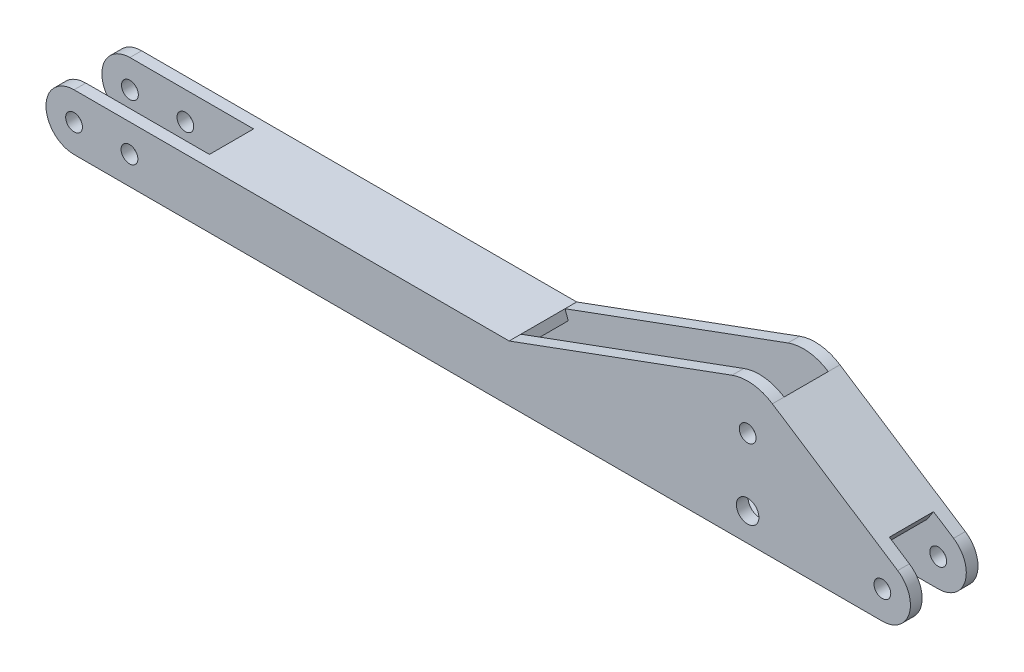
from build123d import *

# Parameters (mm, degrees)
SKETCH1_R           = 38
SKETCH1_R_2         = 51
BOSS_EXTRUDE1_DEPTH = 306
SKETCH2_W           = 687
SKETCH2_H           = 200
CUT_EXTRUDE1_DEPTH  = 214
CUT_EXTRUDE2_START  = -53
SKETCH3_R           = 38
CUT_EXTRUDE2_DEPTH  = 200
SKETCH4_W           = 200
SKETCH4_H           = 174
CUT_EXTRUDE3_DEPTH  = 2690
CUT_EXTRUDE4_REACH  = 866.474
SKETCH5_W           = 1239.54
SKETCH5_H           = 200
SKETCH6_W           = 200
SKETCH6_H           = 296.394261921
CUT_EXTRUDE5_DEPTH  = 2690


with BuildPart() as part:
    # Sketch1 → Boss-Extrude1 (new body)
    with BuildSketch(Plane.XY):
        with BuildLine():
            Line((0, 127), (1970, 127))
            Line((1970, 127), (2979.369630846, 497.448307224))
            ThreePointArc((2979.369630846, 497.448307224), (3073.168771089, 508.686543606), (3162.047709692, 476.669189876))
            Line((3162.047709692, 476.669189876), (3729.41492259, 106.351156655))
            ThreePointArc((3729.41492259, 106.351156655), (3781.728379795, -36.210517152), (3660, -127))
            Line((3660, -127), (0, -127))
            ThreePointArc((0, -127), (-127, 0), (0, 127))
        make_face()
        Circle(SKETCH1_R, mode=Mode.SUBTRACT)
        with Locations((3660, 0)):
            Circle(SKETCH1_R, mode=Mode.SUBTRACT)
        with Locations((3050, 0)):
            Circle(SKETCH1_R_2, mode=Mode.SUBTRACT)
        with Locations((3050, 305)):
            Circle(SKETCH1_R, mode=Mode.SUBTRACT)
        with Locations((251, 0)):
            Circle(SKETCH1_R, mode=Mode.SUBTRACT)
    extrude(amount=BOSS_EXTRUDE1_DEPTH)

    # Sketch2 → Cut-Extrude1 (cut)
    with BuildSketch(Plane(origin=(0, 127, 0), x_dir=(1, 0, 0), z_dir=(0, 1, 0))):
        with Locations((216.5, -153)):
            Rectangle(SKETCH2_W, SKETCH2_H)
    extrude(amount=-CUT_EXTRUDE1_DEPTH, mode=Mode.SUBTRACT)

    # Sketch3 → Cut-Extrude2 (cut)
    with BuildSketch(Plane.XY.offset(306).offset(CUT_EXTRUDE2_START)):
        with BuildLine():
            Line((3729.41492259, 106.351156655), (3638.66, 165.586487274))
            Line((3638.66, 165.586487274), (3447.690113035, -127))
            Line((3447.690113035, -127), (3660, -127))
            ThreePointArc((3660, -127), (3781.728379795, -36.210517152), (3729.41492259, 106.351156655))
        make_face()
        with Locations((3660, 0)):
            Circle(SKETCH3_R, mode=Mode.SUBTRACT)
    extrude(amount=-CUT_EXTRUDE2_DEPTH, mode=Mode.SUBTRACT)

    # Sketch4 → Cut-Extrude3 (cut)
    with BuildSketch(Plane.ZY.offset(-560)):
        with Locations((153, 0)):
            Rectangle(SKETCH4_W, SKETCH4_H)
    extrude(amount=-CUT_EXTRUDE3_DEPTH, mode=Mode.SUBTRACT)

    # Cut-Extrude4: up to this face of the body (flat: up to its plane)
    cut_extrude4_end = Plane(part.part.faces().sort_by_distance((1578.739865975, -87, 153))[0])
    # Sketch5 → Cut-Extrude4 (cut, up to the picked face)
    with BuildSketch(Plane(origin=(192.774928242, -525.258597117, 0), x_dir=(0.93877223, 0.344538386, 0), z_dir=(-0.344538386, 0.93877223, 0)), mode=Mode.PRIVATE) as cut_extrude4_sk1:
        with Locations((2512.907668844, -153)):
            Rectangle(SKETCH5_W, SKETCH5_H)
    cut_extrude4_tool1 = split(extrude(cut_extrude4_sk1.sketch, amount=-CUT_EXTRUDE4_REACH, mode=Mode.PRIVATE), bisect_by=cut_extrude4_end, keep=Keep.BOTH, mode=Mode.PRIVATE)
    add(cut_extrude4_tool1.solids().sort_by_distance((2551.822865, 340.534556, 153))[0], mode=Mode.SUBTRACT)

    # Sketch6 → Cut-Extrude5 (cut)
    with BuildSketch(Plane(origin=(2475.844419588, -1615.972539797, 0), x_dir=(0, 0, -1), z_dir=(0.837410682, -0.546574194, 0))):
        with Locations((-153, 1926.264417691)):
            Rectangle(SKETCH6_W, SKETCH6_H)
    extrude(amount=-CUT_EXTRUDE5_DEPTH, mode=Mode.SUBTRACT)


solid = part.part
